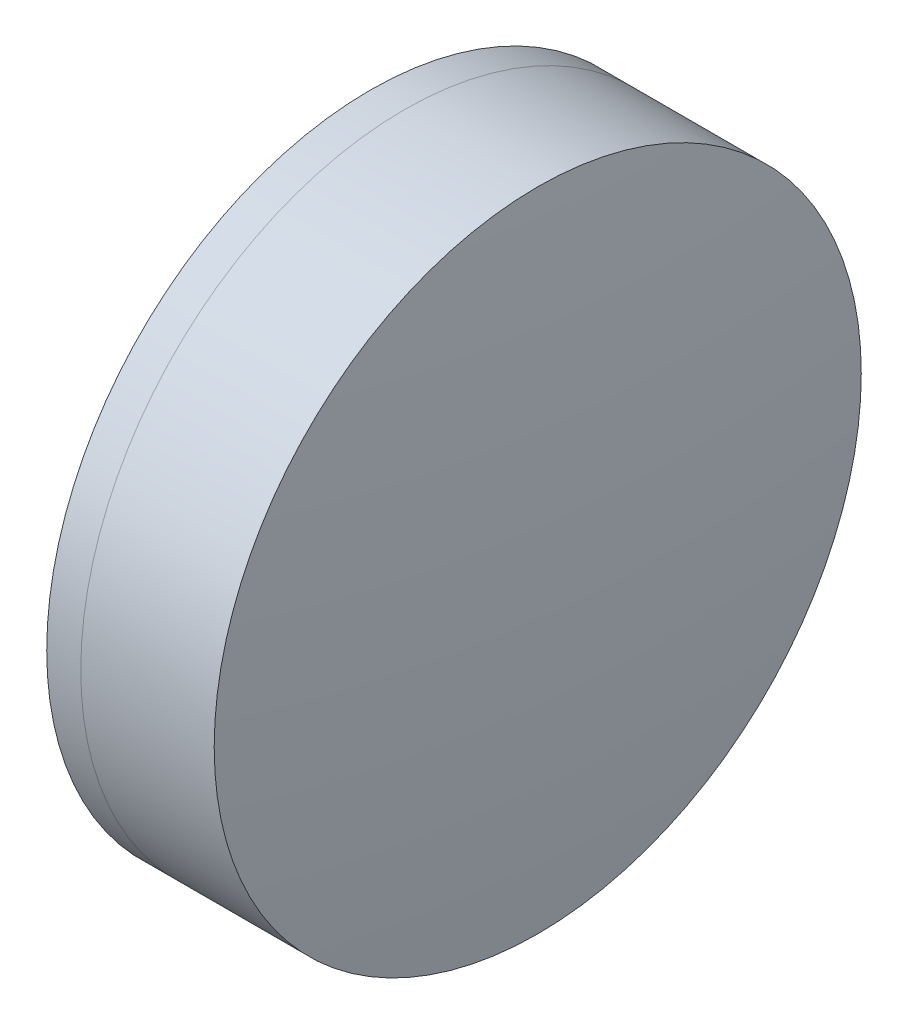
from build123d import *


with BuildPart() as part:
    # 草图1 one side → 旋转1 (revolve)
    with BuildSketch(Plane(origin=(0, 0, 0), x_dir=(1, 0, 0), z_dir=(0, 1, 0)), mode=Mode.PRIVATE) as revolve_1_sk:
        with BuildLine():
            ThreePointArc((88.991949675, 25.4), (83.810880554, 13.166825018), (82.042048651, 0))
            Line((82.042048651, 0), (101.042048651, 0))
            ThreePointArc((101.042048651, 0), (98.622970645, 13.537783426), (91.66514509, 25.4))
            Line((91.66514509, 25.4), (88.991949675, 25.4))
        make_face()
    revolve(revolve_1_sk.sketch.rotate(Axis((-0.816062176, 0, 0), (1, 0, 0)), 180), axis=Axis((-0.816062176, 0, 0), (1, 0, 0)))  # turned: the seam where the file's is


with BuildPart() as body_2:
    # 草图2 one side → 旋转2 (revolve)
    with BuildSketch(Plane(origin=(0, 0, 0), x_dir=(1, 0, 0), z_dir=(0, 1, 0))):
        with BuildLine():
            Line((102.139519199, 25.4), (91.66514509, 25.4))
            ThreePointArc((91.66514509, 25.4), (98.622970645, 13.537783426), (101.042048651, 0))
            Line((101.042048651, 0), (103.542048651, 0))
            ThreePointArc((103.542048651, 0), (103.191149425, 12.719346375), (102.139519199, 25.4))
        make_face()
    revolve(axis=Axis((-0.551919993, 0, 0), (1, 0, 0)))


solid = Compound([part.part, body_2.part])
